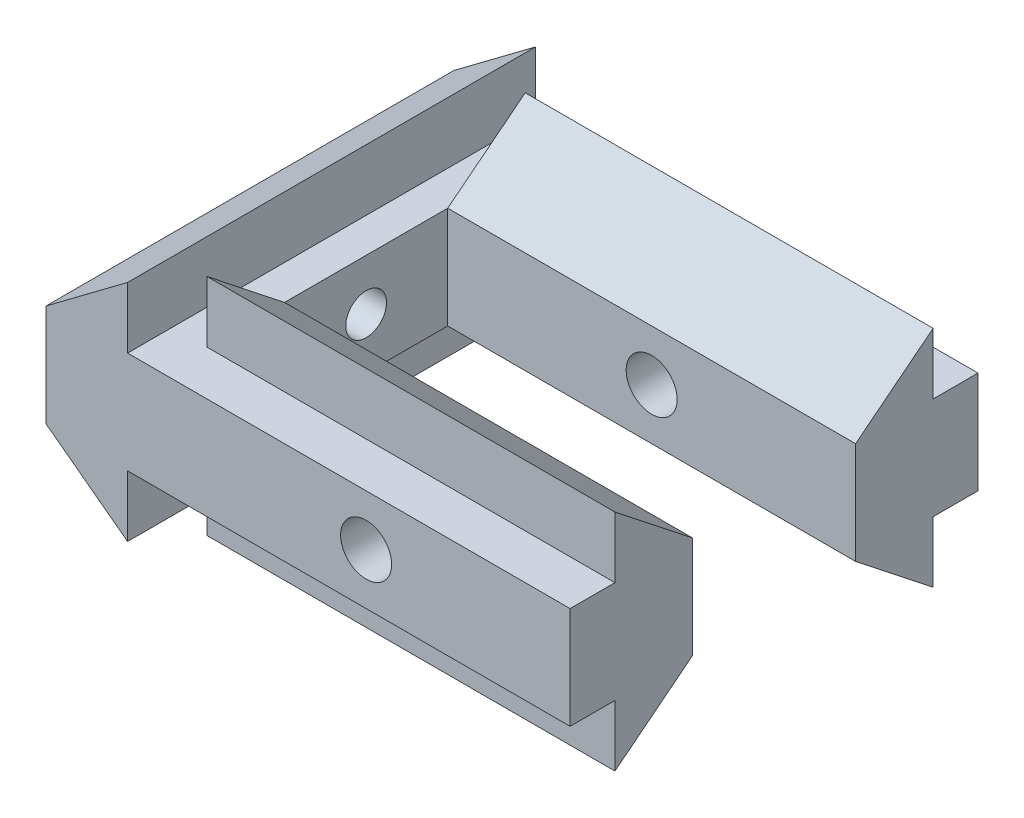
from build123d import *

# Parameters (mm, degrees)
BOSS_EXTRU_1_DEPTH      = 20
ESQUISSE1_R             = 1
ENL_V_MAT_EXTRU_1_DEPTH = 6.695841166
BOSS_EXTRU_2_DEPTH      = 20
ESQUISSE3_R             = 1.25
ENL_V_MAT_EXTRU_2_DEPTH = 21


with BuildPart() as part:
    # ProfileRainureEsquisse → Boss.-Extru.1 (new body)
    with BuildSketch(Plane.XY):
        Polygon((0, 0), (0, 5), (4, 8), (4, 5), (5.695841166, 5), (5.695841166, 0), (4, 0), (4, -3), align=None)
    extrude(amount=BOSS_EXTRU_1_DEPTH)

    # Esquisse1 → Enlèv. mat.-Extru.1 (cut, through all)
    with BuildSketch(Plane(origin=(5.695841166, 0, 0), x_dir=(0, 0, -1), z_dir=(1, 0, 0))):
        with Locations((-10, 2.5)):
            Circle(ESQUISSE1_R)
    extrude(amount=-ENL_V_MAT_EXTRU_1_DEPTH, mode=Mode.SUBTRACT)

    # Esquisse2 → Boss.-Extru.2 (add)
    with BuildSketch(Plane(origin=(5.695841166, 0, 0), x_dir=(0, 0, -1), z_dir=(1, 0, 0))):
        Polygon((-14, 0), (-14, 5), (-17.8, 8), (-17.8, 5), (-20, 5), (-20, 0), (-17.8, 0), (-17.8, -3), align=None)
        Polygon((-6, 5), (-6, 0), (-2.2, -3), (-2.2, 0), (0, 0), (0, 5), (-2.2, 5), (-2.2, 8), align=None)
    extrude(amount=BOSS_EXTRU_2_DEPTH)

    # Esquisse3 → Enlèv. mat.-Extru.2 (cut, through all)
    with BuildSketch(Plane.XY.offset(20)):
        with Locations((15.695841166, 2.5)):
            Circle(ESQUISSE3_R)
    extrude(amount=-ENL_V_MAT_EXTRU_2_DEPTH, mode=Mode.SUBTRACT)


solid = part.part
